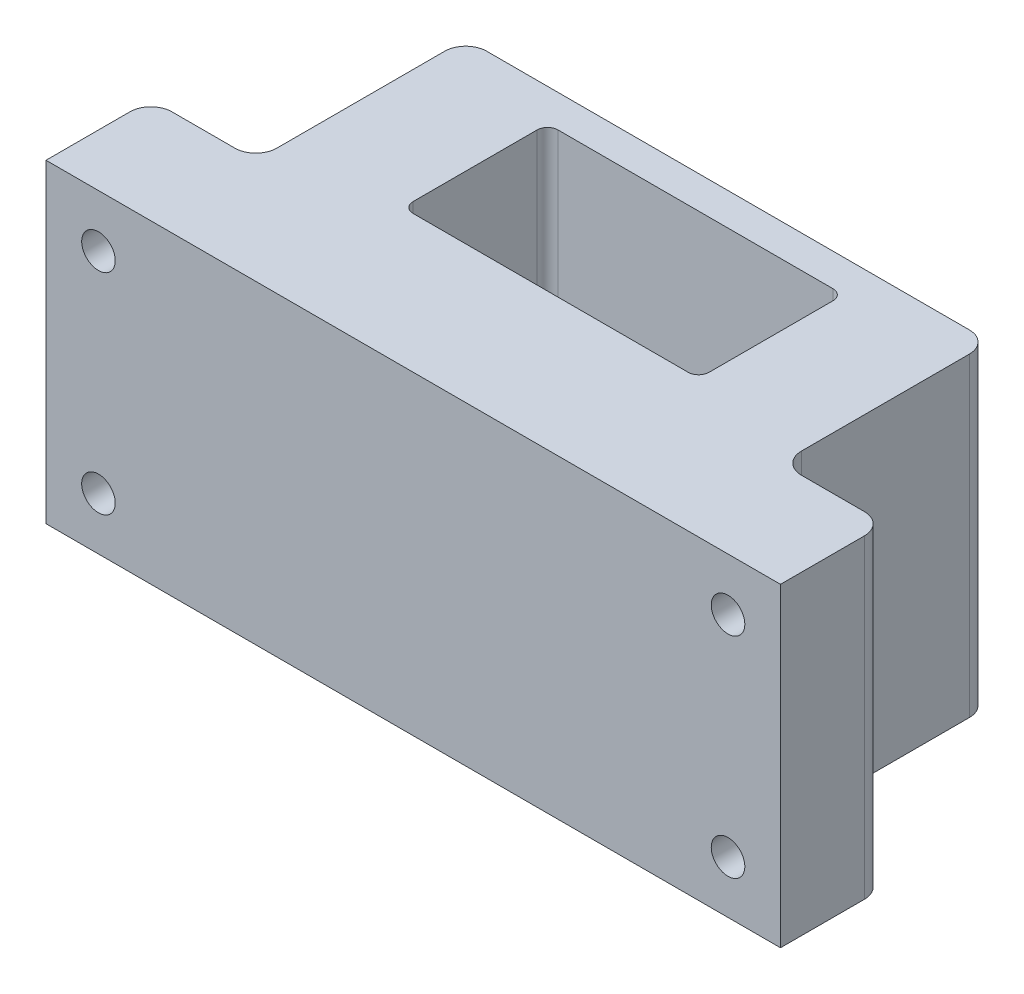
from build123d import *

# Parameters (mm, degrees)
SKETCH_1_W          = 70
SKETCH_1_H          = 30
EXTRUDE_1_DEPTH     = 30
SKETCH_2_R          = 1.6
CUT_EXTRUDE_1_DEPTH = 31
SKETCH_3_W          = 28.2
SKETCH_3_H          = 13.8
CUT_EXTRUDE_2_DEPTH = 31
EXTRUDE_2_DEPTH     = 1.2
SKETCH_5_R          = 1.1
CUT_EXTRUDE_3_DEPTH = 3.1
SKETCH_6_W          = 10
SKETCH_6_H          = 30
CUT_EXTRUDE_4_DEPTH = 20
SKETCH_7_R          = 1.8
CUT_EXTRUDE_5_DEPTH = 10.2
SKETCH_8_R          = 2.15
CUT_EXTRUDE_6_DEPTH = 0.8
SKETCH_9_R          = 1.8
CUT_EXTRUDE_7_DEPTH = 10.2
SKETCH_10_R         = 2.15
CUT_EXTRUDE_8_DEPTH = 0.8
FILLET_1_R          = 2
FILLET_2_R          = 1


with BuildPart() as part:
    # 草图1 → 凸台-拉伸1 (new body)
    with BuildSketch(Plane.XY):
        with Locations((35, 15)):
            Rectangle(SKETCH_1_W, SKETCH_1_H)
    extrude(amount=EXTRUDE_1_DEPTH)

    # 草图2 → 切除-拉伸1 (cut, through all)
    with BuildSketch(Plane.XY.offset(30)):
        with Locations((5, 5)):
            Circle(SKETCH_2_R)
        with Locations((65, 5)):
            Circle(SKETCH_2_R)
        with Locations((65, 25)):
            Circle(SKETCH_2_R)
        with Locations((5, 25)):
            Circle(SKETCH_2_R)
    extrude(amount=-CUT_EXTRUDE_1_DEPTH, mode=Mode.SUBTRACT)

    # 草图3 → 切除-拉伸2 (cut, through all)
    with BuildSketch(Plane.XZ):
        with Locations((35, 10)):
            Rectangle(SKETCH_3_W, SKETCH_3_H)
    extrude(amount=-CUT_EXTRUDE_2_DEPTH, mode=Mode.SUBTRACT)

    # 草图4 → 凸台-拉伸2 (add)
    with BuildSketch(Plane.XZ):
        with BuildLine():
            ThreePointArc((20.9, 10), (22.92096321, 14.87903679), (27.8, 16.9))
            Line((27.8, 16.9), (20.9, 16.9))
            Line((20.9, 16.9), (20.9, 10))
        make_face()
        with BuildLine():
            ThreePointArc((27.8, 3.1), (22.92096321, 5.12096321), (20.9, 10))
            Line((20.9, 10), (20.9, 3.1))
            Line((20.9, 3.1), (27.8, 3.1))
        make_face()
        with BuildLine():
            Line((49.1, 16.9), (42.2, 16.9))
            ThreePointArc((42.2, 16.9), (47.079036757, 14.879036823), (49.1, 10.000000094))
            Line((49.1, 10.000000094), (49.1, 16.9))
        make_face()
        with BuildLine():
            Line((49.1, 3.1), (49.1, 10.000000094))
            ThreePointArc((49.1, 10.000000094), (47.079036823, 5.120963243), (42.2, 3.1))
            Line((42.2, 3.1), (49.1, 3.1))
        make_face()
    extrude(amount=-EXTRUDE_2_DEPTH)

    # 草图5 → 切除-拉伸3 (cut)
    with BuildSketch(Plane(origin=(0, 0, 0), x_dir=(-1, 0, 0), z_dir=(0, 0, -1))):
        with Locations((-45.8, 11.1)):
            Circle(SKETCH_5_R)
        with Locations((-24.2, 11.1)):
            Circle(SKETCH_5_R)
    extrude(amount=-CUT_EXTRUDE_3_DEPTH, mode=Mode.SUBTRACT)

    # 草图6 → 切除-拉伸4 (cut)
    with BuildSketch(Plane(origin=(0, 0, 0), x_dir=(-1, 0, 0), z_dir=(0, 0, -1))):
        with Locations((-65, 15)):
            Rectangle(SKETCH_6_W, SKETCH_6_H)
        with Locations((-5, 15)):
            Rectangle(SKETCH_6_W, SKETCH_6_H)
    extrude(amount=-CUT_EXTRUDE_4_DEPTH, mode=Mode.SUBTRACT)

    # 草图7 → 切除-拉伸5 (cut)
    with BuildSketch(Plane.XZ):
        with Locations((54, 10)):
            Circle(SKETCH_7_R)
        with Locations((16, 10)):
            Circle(SKETCH_7_R)
        with Locations((54, 25)):
            Circle(SKETCH_7_R)
        with Locations((16, 25)):
            Circle(SKETCH_7_R)
    extrude(amount=-CUT_EXTRUDE_5_DEPTH, mode=Mode.SUBTRACT)

    # 草图8 → 切除-拉伸6 (cut)
    with BuildSketch(Plane.XZ):
        with Locations((54, 10)):
            Circle(SKETCH_8_R)
        with Locations((16, 10)):
            Circle(SKETCH_8_R)
        with Locations((54, 25)):
            Circle(SKETCH_8_R)
        with Locations((16, 25)):
            Circle(SKETCH_8_R)
    extrude(amount=-CUT_EXTRUDE_6_DEPTH, mode=Mode.SUBTRACT)

    # 草图9 → 切除-拉伸7 (cut)
    with BuildSketch(Plane(origin=(0, 0, 0), x_dir=(-1, 0, 0), z_dir=(0, 0, -1))):
        with Locations((-54, 23)):
            Circle(SKETCH_9_R)
        with Locations((-16, 23)):
            Circle(SKETCH_9_R)
    extrude(amount=-CUT_EXTRUDE_7_DEPTH, mode=Mode.SUBTRACT)

    # 草图10 → 切除-拉伸8 (cut)
    with BuildSketch(Plane(origin=(0, 0, 0), x_dir=(-1, 0, 0), z_dir=(0, 0, -1))):
        with Locations((-54, 23)):
            Circle(SKETCH_10_R)
        with Locations((-16, 23)):
            Circle(SKETCH_10_R)
    extrude(amount=-CUT_EXTRUDE_8_DEPTH, mode=Mode.SUBTRACT)

    # 圆角1
    fillet_1_edges = [part.edges().sort_by_distance(p)[0] for p in [
        (60, 15, 0),
        (70, 15, 20),
        (60, 15, 20),
        (10, 15, 0),
        (10, 15, 20),
        (0, 15, 20),
    ]]
    fillet(fillet_1_edges, radius=FILLET_1_R)

    # 圆角2
    fillet_2_edges = [part.edges().sort_by_distance(p)[0] for p in [
        (20.9, 15.6, 3.1),
        (20.9, 15.6, 16.9),
        (49.1, 15.6, 16.9),
        (49.1, 15.6, 3.1),
    ]]
    fillet(fillet_2_edges, radius=FILLET_2_R)


solid = part.part
